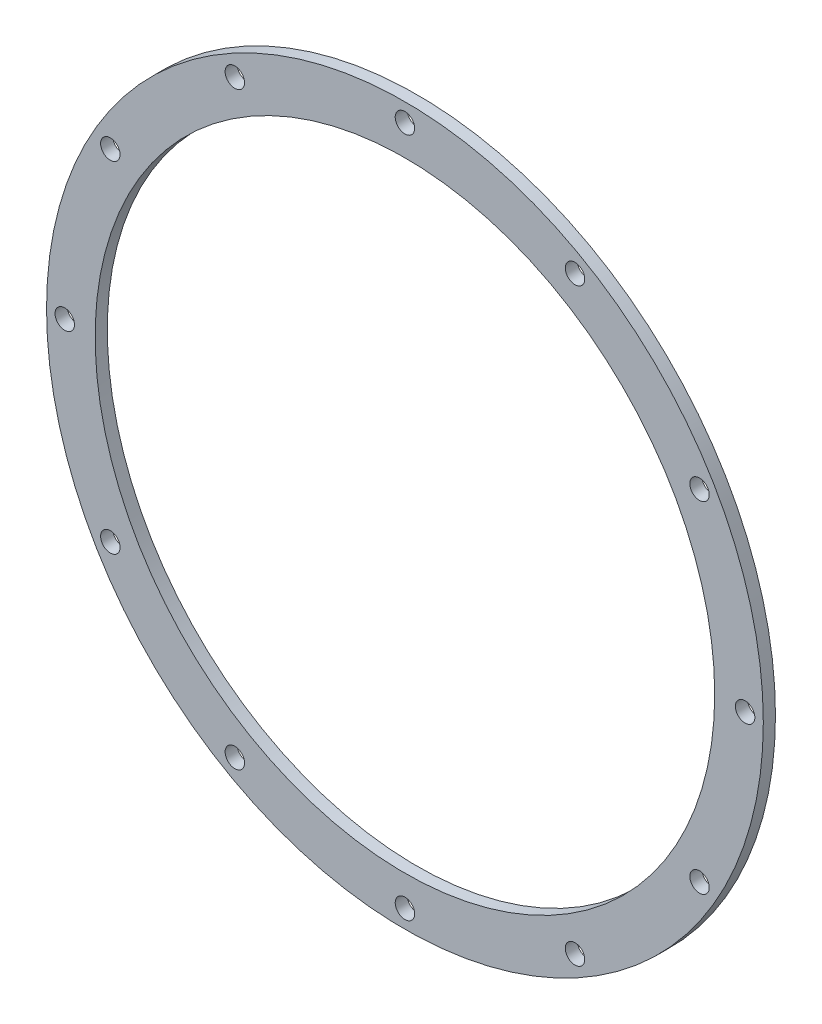
from build123d import *

# Parameters (mm, degrees)
SKETCH_1_R      = 59
SKETCH_1_R_2    = 51
SKETCH_1_R_3    = 1.6
EXTRUDE_1_DEPTH = 2


with BuildPart() as part:
    # 草图1 → 凸台-拉伸1 (new body)
    with BuildSketch(Plane.XY):
        Circle(SKETCH_1_R)
        Circle(SKETCH_1_R_2, mode=Mode.SUBTRACT)
        with Locations((0, 56)):
            Circle(SKETCH_1_R_3, mode=Mode.SUBTRACT)
        with Locations((28, 48.497422612)):
            Circle(SKETCH_1_R_3, mode=Mode.SUBTRACT)
        with Locations((48.497422612, 28)):
            Circle(SKETCH_1_R_3, mode=Mode.SUBTRACT)
        with Locations((56, 0)):
            Circle(SKETCH_1_R_3, mode=Mode.SUBTRACT)
        with Locations((48.497422612, -28)):
            Circle(SKETCH_1_R_3, mode=Mode.SUBTRACT)
        with Locations((28, -48.497422612)):
            Circle(SKETCH_1_R_3, mode=Mode.SUBTRACT)
        with Locations((0, -56)):
            Circle(SKETCH_1_R_3, mode=Mode.SUBTRACT)
        with Locations((-28, -48.497422612)):
            Circle(SKETCH_1_R_3, mode=Mode.SUBTRACT)
        with Locations((-48.497422612, -28)):
            Circle(SKETCH_1_R_3, mode=Mode.SUBTRACT)
        with Locations((-56, 0)):
            Circle(SKETCH_1_R_3, mode=Mode.SUBTRACT)
        with Locations((-48.497422612, 28)):
            Circle(SKETCH_1_R_3, mode=Mode.SUBTRACT)
        with Locations((-28, 48.497422612)):
            Circle(SKETCH_1_R_3, mode=Mode.SUBTRACT)
    extrude(amount=EXTRUDE_1_DEPTH)


solid = part.part
